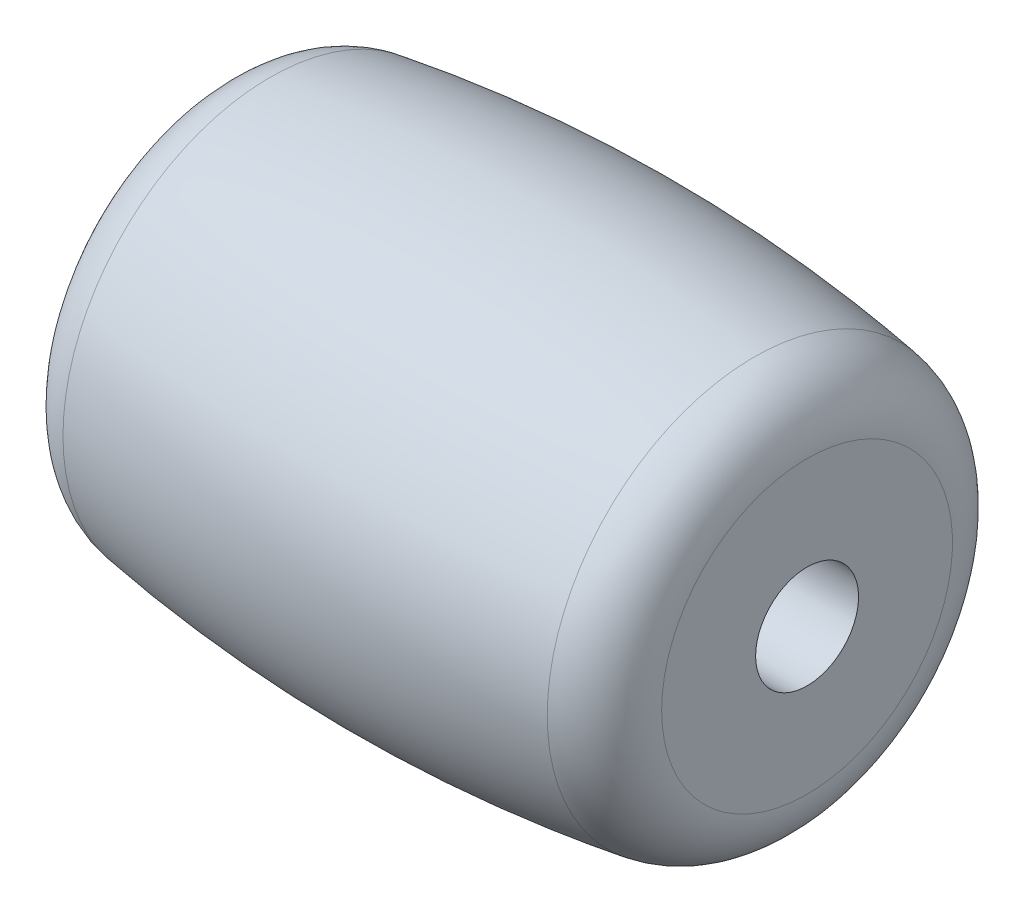
from build123d import *


with BuildPart() as part:
    # Sketch1 → Revolve1 (revolve)
    with BuildSketch(Plane.XY):
        with BuildLine():
            Line((-9.4615, 1.651), (9.4615, 1.651))
            Line((9.4615, 1.651), (9.4615, 4.665196385))
            ThreePointArc((9.4615, 4.665196385), (8.979985818, 5.966811082), (7.76729918, 6.641679843))
            ThreePointArc((7.76729918, 6.641679843), (0, 7.239), (-7.76729918, 6.641679843))
            ThreePointArc((-7.76729918, 6.641679843), (-8.979985818, 5.966811082), (-9.4615, 4.665196385))
            Line((-9.4615, 4.665196385), (-9.4615, 1.651))
        make_face()
    revolve(axis=Axis((0, 0, 0), (1, 0, 0)))


solid = part.part
